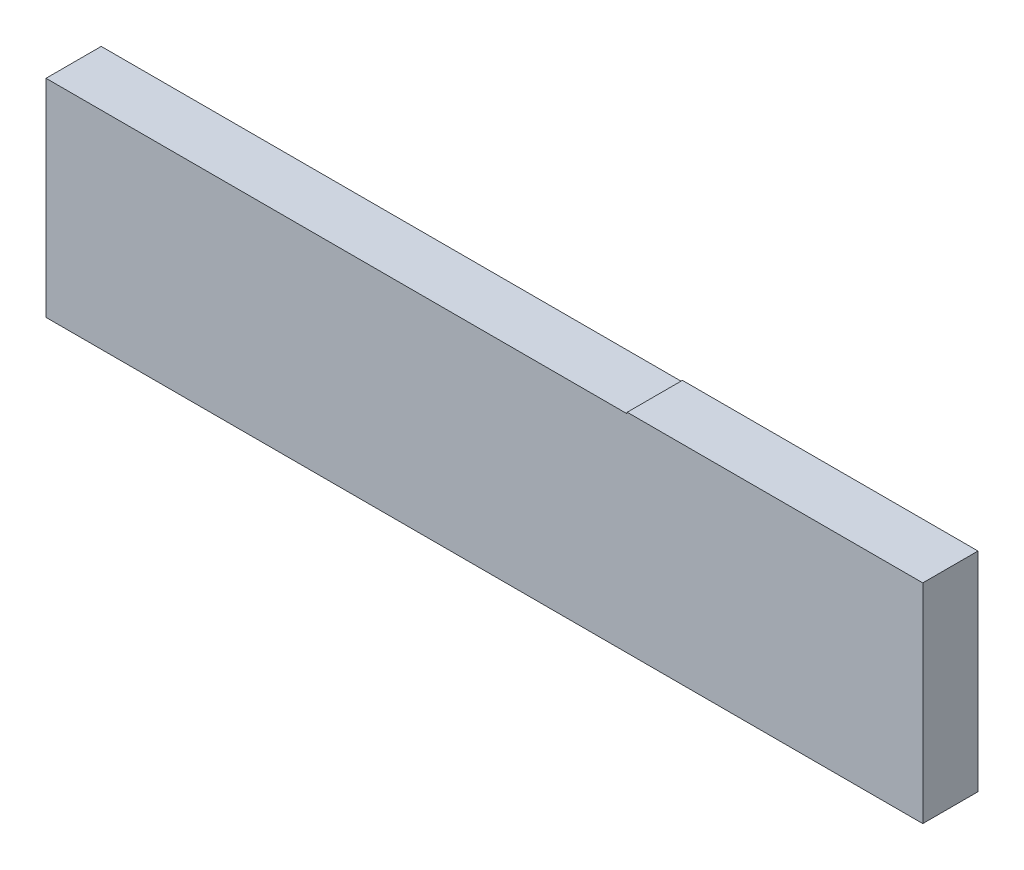
from build123d import *

# Parameters (mm, degrees)
AUFSATZ_LINEAR_AUSTRAGEN1_DEPTH = 4


with BuildPart() as part:
    # Skizze1 → Aufsatz-Linear austragen1 (new body)
    with BuildSketch(Plane.XY):
        Polygon((42.094934725, 15), (42.094934725, 15.1), (63.502314547, 15.1), (63.502314547, 0), (42.094934725, 0), (0, 0), (0, 15), align=None)
    extrude(amount=AUFSATZ_LINEAR_AUSTRAGEN1_DEPTH)


solid = part.part
